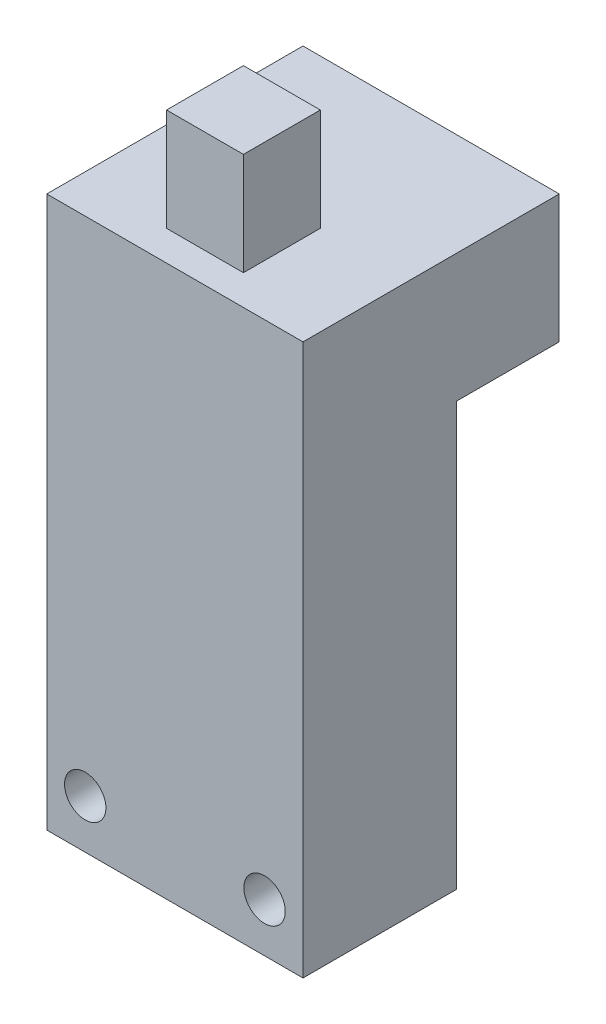
from build123d import *

# Parameters (mm, degrees)
SKETCH1_W           = 20
SKETCH1_H           = 20
BOSS_EXTRUDE1_DEPTH = 10
SKETCH2_W           = 6
SKETCH2_H           = 6
BOSS_EXTRUDE2_DEPTH = 8
SKETCH3_W           = 20
SKETCH3_H           = 12
BOSS_EXTRUDE3_DEPTH = 33
SKETCH4_R           = 1.615
CUT_EXTRUDE1_DEPTH  = 21


with BuildPart() as part:
    # Sketch1 → Boss-Extrude1 (new body)
    with BuildSketch(Plane(origin=(0, 0, 0), x_dir=(1, 0, 0), z_dir=(0, 1, 0))):
        with Locations((10, 10)):
            Rectangle(SKETCH1_W, SKETCH1_H)
    extrude(amount=BOSS_EXTRUDE1_DEPTH)

    # Sketch2 → Boss-Extrude2 (add)
    with BuildSketch(Plane(origin=(0, 10, 0), x_dir=(1, 0, 0), z_dir=(0, 1, 0))):
        with Locations((10, 5.35)):
            Rectangle(SKETCH2_W, SKETCH2_H)
    extrude(amount=BOSS_EXTRUDE2_DEPTH)

    # Sketch3 → Boss-Extrude3 (add)
    with BuildSketch(Plane.XZ):
        with Locations((10, -6)):
            Rectangle(SKETCH3_W, SKETCH3_H)
    extrude(amount=BOSS_EXTRUDE3_DEPTH)

    # Sketch4 → Cut-Extrude1 (cut, through all)
    with BuildSketch(Plane.XY):
        with Locations((17, -29.2)):
            Circle(SKETCH4_R)
        with Locations((3, -29.2)):
            Circle(SKETCH4_R)
    extrude(amount=-CUT_EXTRUDE1_DEPTH, mode=Mode.SUBTRACT)


solid = part.part
